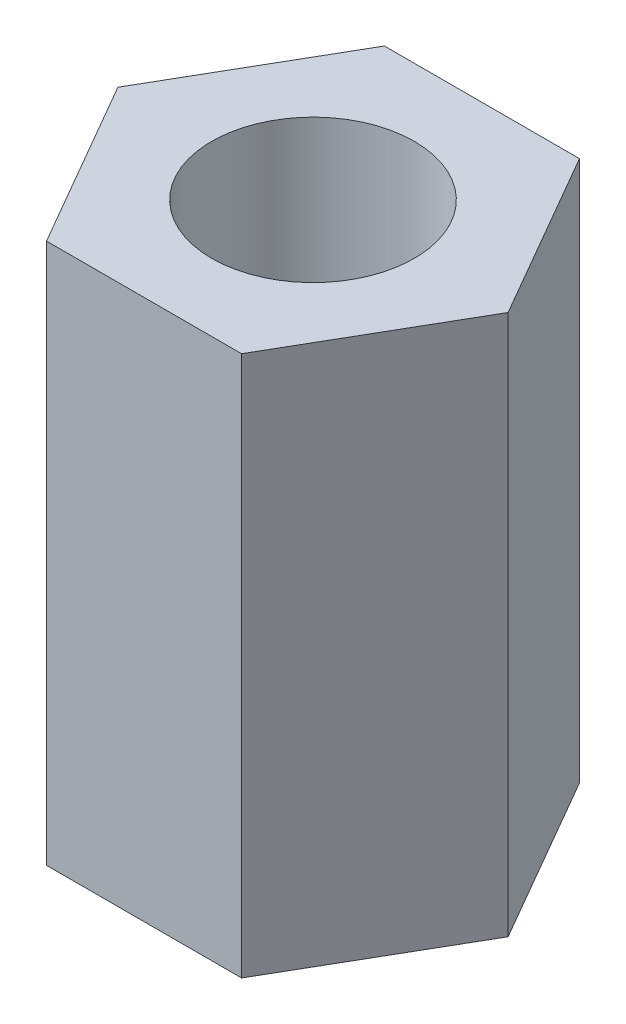
from build123d import *

# Parameters (mm, degrees)
CROQUIS1_R              = 1.5
SALIENTE_EXTRUIR1_DEPTH = 4


with BuildPart() as part:
    # Croquis1 → Saliente-Extruir1 (new body, symmetric)
    with BuildSketch(Plane(origin=(0, 0, 0), x_dir=(1, 0, 0), z_dir=(0, 1, 0))):
        Polygon((1.443375673, -2.5), (2.886751346, 0), (1.443375673, 2.5), (-1.443375673, 2.5), (-2.886751346, 0), (-1.443375673, -2.5), align=None)
        Circle(CROQUIS1_R, mode=Mode.SUBTRACT)
    extrude(amount=SALIENTE_EXTRUIR1_DEPTH, both=True)


solid = part.part
